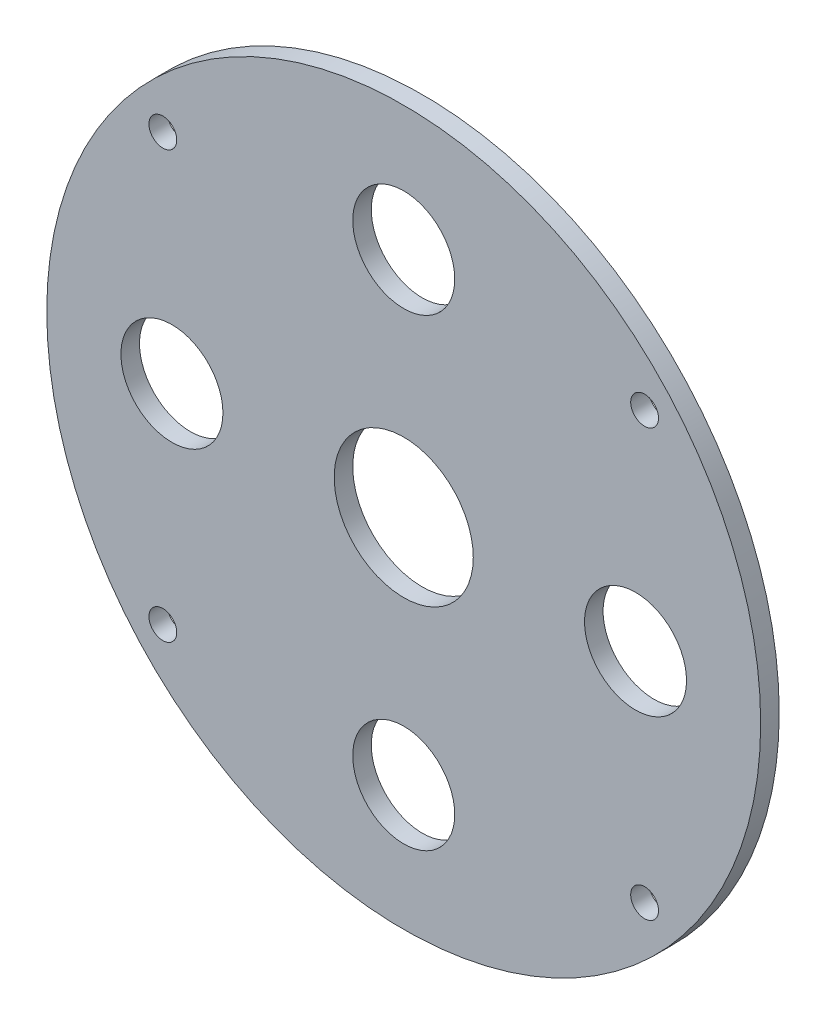
from build123d import *

# Parameters (mm, degrees)
MODEL_R             = 38.5
MODEL_R_2           = 5.5
MODEL_R_3           = 7.5
MODEL_R_4           = 1.5
BOSS_EXTRUDE1_DEPTH = 2


with BuildPart() as part:
    # Model → Boss-Extrude1 (new body)
    with BuildSketch(Plane.XY):
        Circle(MODEL_R)
        with Locations((-25, 0)):
            Circle(MODEL_R_2, mode=Mode.SUBTRACT)
        with Locations((0, 25)):
            Circle(MODEL_R_2, mode=Mode.SUBTRACT)
        with Locations((0, -25)):
            Circle(MODEL_R_2, mode=Mode.SUBTRACT)
        with Locations((25, 0)):
            Circle(MODEL_R_2, mode=Mode.SUBTRACT)
        Circle(MODEL_R_3, mode=Mode.SUBTRACT)
        with Locations((25.980762114, -23)):
            Circle(MODEL_R_4, mode=Mode.SUBTRACT)
        with Locations((-25.980762114, -23)):
            Circle(MODEL_R_4, mode=Mode.SUBTRACT)
        with Locations((25.980762114, 23)):
            Circle(MODEL_R_4, mode=Mode.SUBTRACT)
        with Locations((-25.980762114, 23)):
            Circle(MODEL_R_4, mode=Mode.SUBTRACT)
    extrude(amount=BOSS_EXTRUDE1_DEPTH)


solid = part.part
